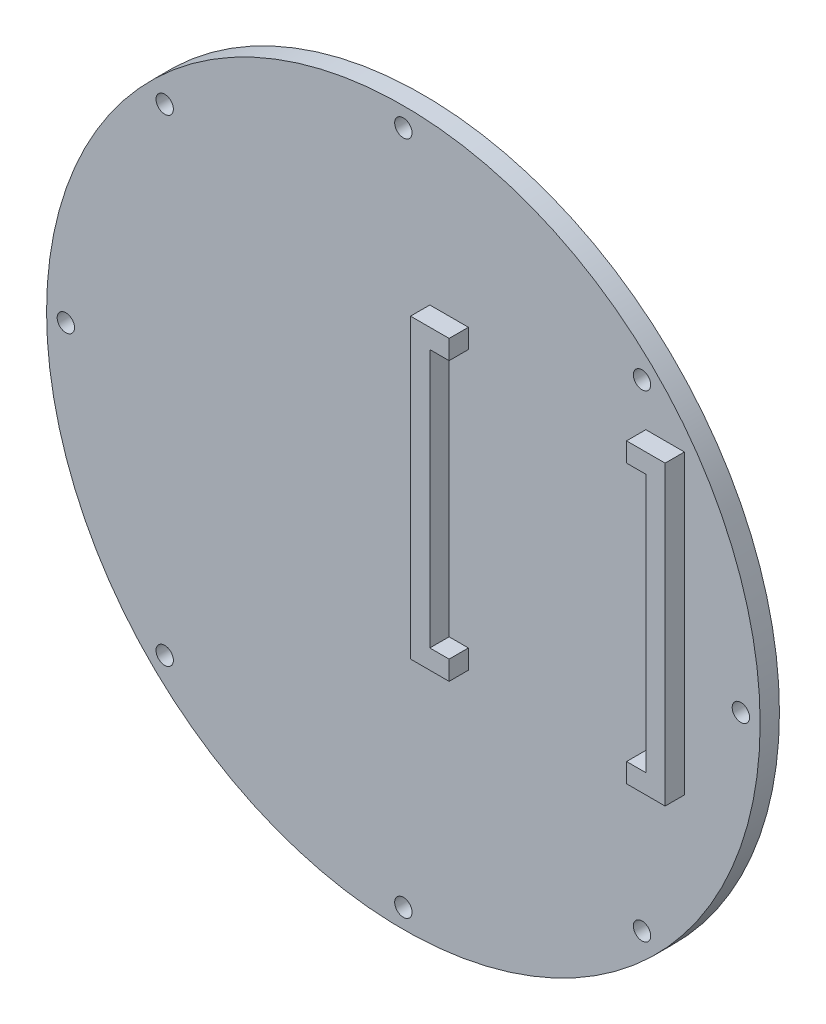
from build123d import *

# Parameters (mm, degrees)
SKETCH1_R           = 92.5
BOSS_EXTRUDE1_DEPTH = 5
BOSS_EXTRUDE2_DEPTH = 5
CUT_EXTRUDE4_REACH  = 12
SKETCH13_R          = 2.25


with BuildPart() as part:
    # Sketch1 → Boss-Extrude1 (new body)
    with BuildSketch(Plane.XY):
        Circle(SKETCH1_R)
    extrude(amount=BOSS_EXTRUDE1_DEPTH)

    # Sketch12 → Boss-Extrude2 (add)
    with BuildSketch(Plane.XY.offset(5)):
        Polygon((62.861769108, -20.84153395), (67.861769108, -20.84153395), (67.861769108, 46.15846605), (62.861769108, 46.15846605), (62.861769108, 51.15846605), (72.861769108, 51.15846605), (72.861769108, -25.84153395), (62.861769108, -25.84153395), align=None)
        Polygon((11.861769105, 46.15846605), (11.861769105, -20.84153395), (16.861769105, -20.84153395), (16.861769105, -25.84153395), (6.861769105, -25.84153395), (6.861769105, 51.15846605), (16.861769105, 51.15846605), (16.861769105, 46.15846605), align=None)
    extrude(amount=BOSS_EXTRUDE2_DEPTH)

    # Sketch13 → Cut-Extrude4 (cut, up to next)
    with BuildSketch(Plane(origin=(0, 0, 0), x_dir=(-1, 0, 0), z_dir=(0, 0, -1)), mode=Mode.PRIVATE) as cut_extrude4_sk1:
        with Locations((-87.5, 0)):
            Circle(SKETCH13_R)
    cut_extrude4_tool1 = extrude(cut_extrude4_sk1.sketch, amount=-CUT_EXTRUDE4_REACH, mode=Mode.PRIVATE) & part.part
    add(cut_extrude4_tool1.solids().sort_by_distance((87.5, 0, 0))[0], mode=Mode.SUBTRACT)
    # Sketch13 → Cut-Extrude4 (cut, up to next)
    with BuildSketch(Plane(origin=(0, 0, 0), x_dir=(-1, 0, 0), z_dir=(0, 0, -1)), mode=Mode.PRIVATE) as cut_extrude4_sk2:
        with Locations((-61.871843354, 61.871843354)):
            Circle(SKETCH13_R)
    cut_extrude4_tool2 = extrude(cut_extrude4_sk2.sketch, amount=-CUT_EXTRUDE4_REACH, mode=Mode.PRIVATE) & part.part
    add(cut_extrude4_tool2.solids().sort_by_distance((61.871843, 61.871843, 0))[0], mode=Mode.SUBTRACT)
    # Sketch13 → Cut-Extrude4 (cut, up to next)
    with BuildSketch(Plane(origin=(0, 0, 0), x_dir=(-1, 0, 0), z_dir=(0, 0, -1)), mode=Mode.PRIVATE) as cut_extrude4_sk3:
        with Locations((0, 87.5)):
            Circle(SKETCH13_R)
    cut_extrude4_tool3 = extrude(cut_extrude4_sk3.sketch, amount=-CUT_EXTRUDE4_REACH, mode=Mode.PRIVATE) & part.part
    add(cut_extrude4_tool3.solids().sort_by_distance((0, 87.5, 0))[0], mode=Mode.SUBTRACT)
    # Sketch13 → Cut-Extrude4 (cut, up to next)
    with BuildSketch(Plane(origin=(0, 0, 0), x_dir=(-1, 0, 0), z_dir=(0, 0, -1)), mode=Mode.PRIVATE) as cut_extrude4_sk4:
        with Locations((61.871843354, 61.871843354)):
            Circle(SKETCH13_R)
    cut_extrude4_tool4 = extrude(cut_extrude4_sk4.sketch, amount=-CUT_EXTRUDE4_REACH, mode=Mode.PRIVATE) & part.part
    add(cut_extrude4_tool4.solids().sort_by_distance((-61.871843, 61.871843, 0))[0], mode=Mode.SUBTRACT)
    # Sketch13 → Cut-Extrude4 (cut, up to next)
    with BuildSketch(Plane(origin=(0, 0, 0), x_dir=(-1, 0, 0), z_dir=(0, 0, -1)), mode=Mode.PRIVATE) as cut_extrude4_sk5:
        with Locations((87.5, 0)):
            Circle(SKETCH13_R)
    cut_extrude4_tool5 = extrude(cut_extrude4_sk5.sketch, amount=-CUT_EXTRUDE4_REACH, mode=Mode.PRIVATE) & part.part
    add(cut_extrude4_tool5.solids().sort_by_distance((-87.5, 0, 0))[0], mode=Mode.SUBTRACT)
    # Sketch13 → Cut-Extrude4 (cut, up to next)
    with BuildSketch(Plane(origin=(0, 0, 0), x_dir=(-1, 0, 0), z_dir=(0, 0, -1)), mode=Mode.PRIVATE) as cut_extrude4_sk6:
        with Locations((61.871843354, -61.871843354)):
            Circle(SKETCH13_R)
    cut_extrude4_tool6 = extrude(cut_extrude4_sk6.sketch, amount=-CUT_EXTRUDE4_REACH, mode=Mode.PRIVATE) & part.part
    add(cut_extrude4_tool6.solids().sort_by_distance((-61.871843, -61.871843, 0))[0], mode=Mode.SUBTRACT)
    # Sketch13 → Cut-Extrude4 (cut, up to next)
    with BuildSketch(Plane(origin=(0, 0, 0), x_dir=(-1, 0, 0), z_dir=(0, 0, -1)), mode=Mode.PRIVATE) as cut_extrude4_sk7:
        with Locations((0, -87.5)):
            Circle(SKETCH13_R)
    cut_extrude4_tool7 = extrude(cut_extrude4_sk7.sketch, amount=-CUT_EXTRUDE4_REACH, mode=Mode.PRIVATE) & part.part
    add(cut_extrude4_tool7.solids().sort_by_distance((0, -87.5, 0))[0], mode=Mode.SUBTRACT)
    # Sketch13 → Cut-Extrude4 (cut, up to next)
    with BuildSketch(Plane(origin=(0, 0, 0), x_dir=(-1, 0, 0), z_dir=(0, 0, -1)), mode=Mode.PRIVATE) as cut_extrude4_sk8:
        with Locations((-61.871843354, -61.871843354)):
            Circle(SKETCH13_R)
    cut_extrude4_tool8 = extrude(cut_extrude4_sk8.sketch, amount=-CUT_EXTRUDE4_REACH, mode=Mode.PRIVATE) & part.part
    add(cut_extrude4_tool8.solids().sort_by_distance((61.871843, -61.871843, 0))[0], mode=Mode.SUBTRACT)


solid = part.part
